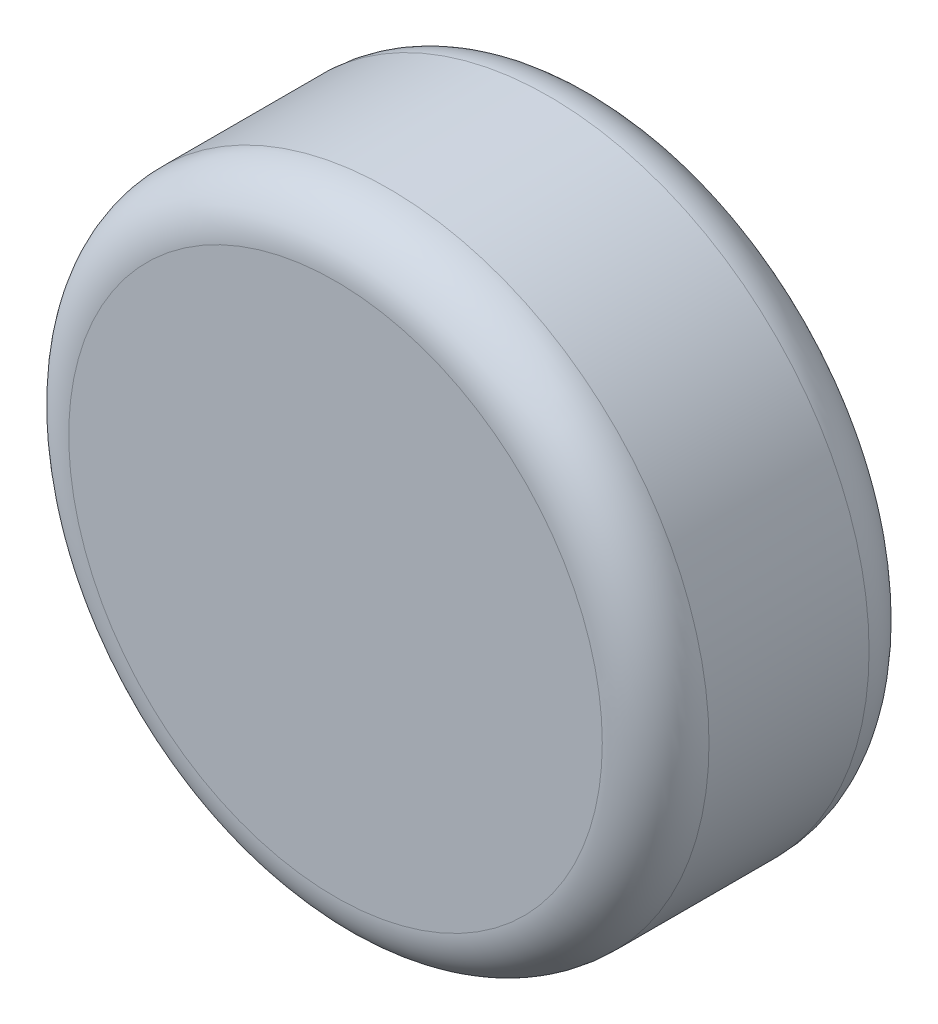
from build123d import *

# Parameters (mm, degrees)
SKETCH1_R           = 30
BOSS_EXTRUDE1_DEPTH = 25
FILLET1_R           = 5


with BuildPart() as part:
    # Sketch1 → Boss-Extrude1 (new body)
    with BuildSketch(Plane.XY):
        Circle(SKETCH1_R)
    extrude(amount=BOSS_EXTRUDE1_DEPTH)

    # Fillet1
    fillet1_edges = [part.edges().sort_by_distance(p)[0] for p in [
        (-30, 0, 0),
        (-30, 0, 25),
    ]]
    fillet(fillet1_edges, radius=FILLET1_R)


solid = part.part
